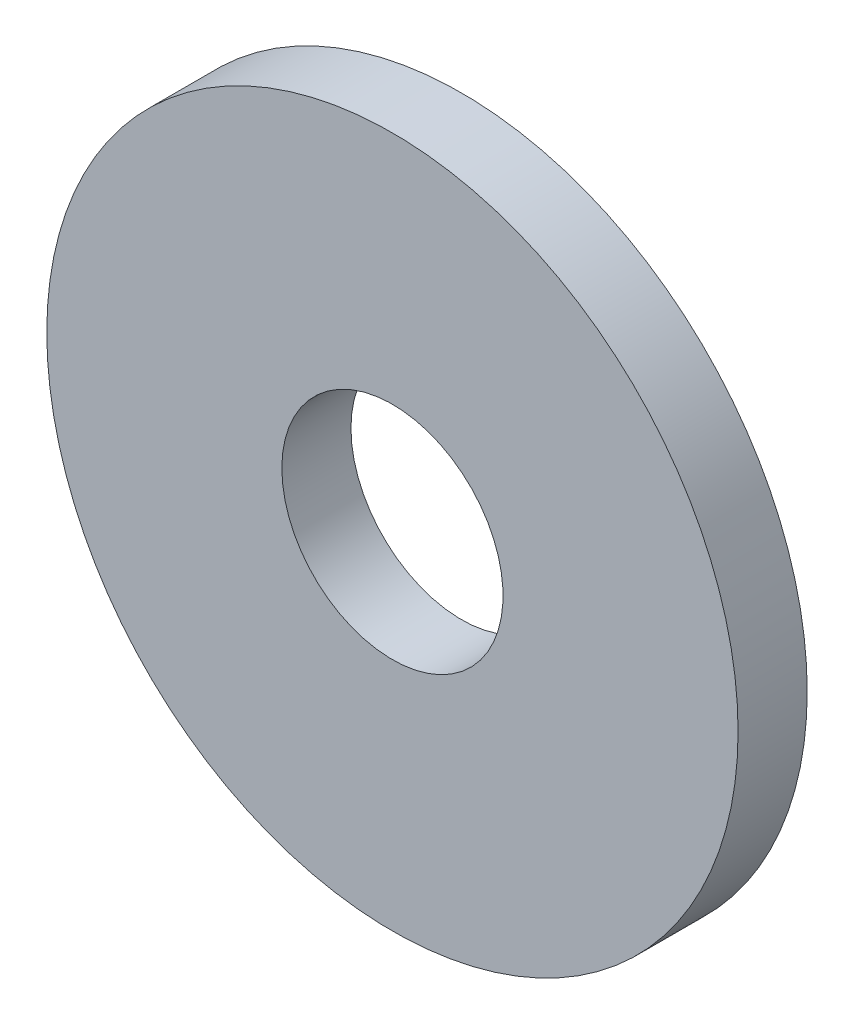
from build123d import *

# Parameters (mm, degrees)
SKETCH1_W = 3.4
SKETCH1_H = 1


with BuildPart() as part:
    # Sketch1 → Revolve1 (revolve)
    with BuildSketch(Plane.XZ):
        with Locations((3.3, 0.5)):
            Rectangle(SKETCH1_W, SKETCH1_H)
    revolve(axis=Axis((0, 0, 1), (0, 0, -1)))


solid = part.part
